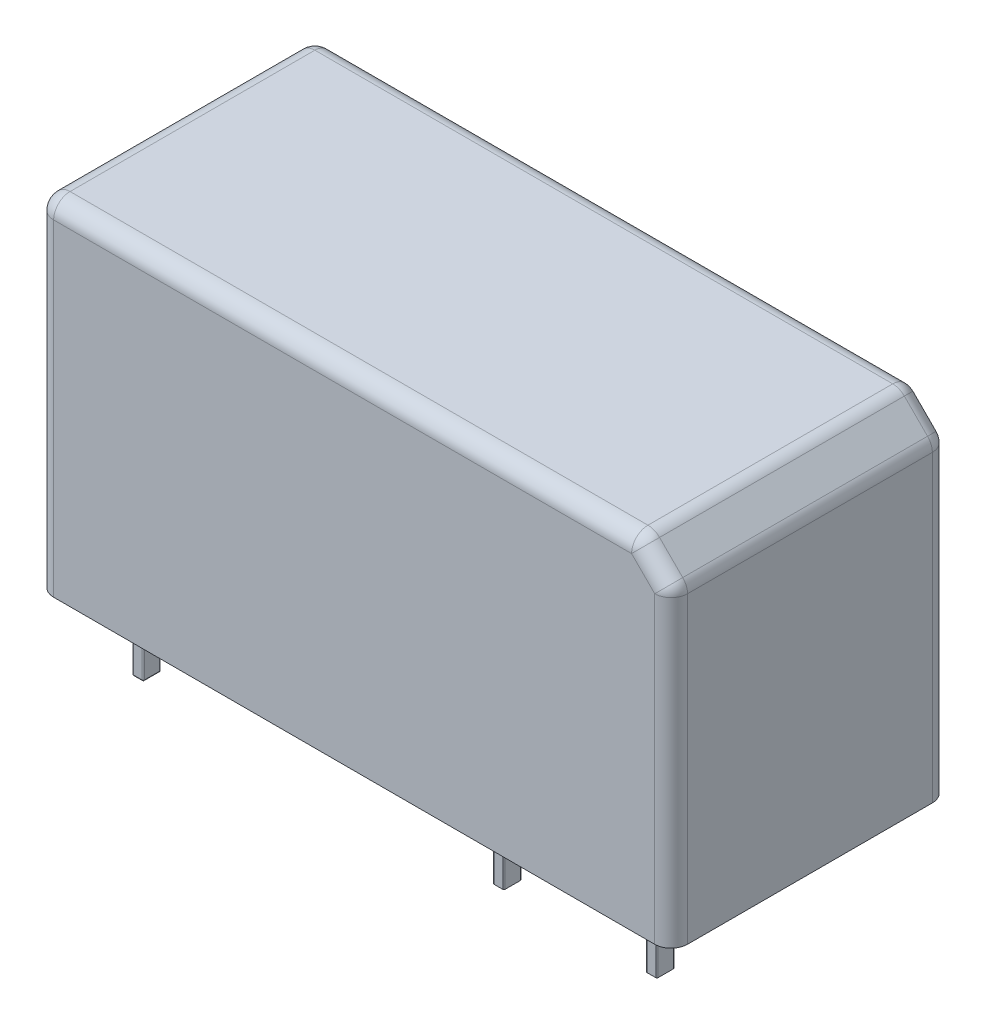
from build123d import *

# Parameters (mm, degrees)
SKETCH_1_W      = 29
SKETCH_1_H      = 12.7
EXTRUDE_1_DEPTH = 15.7
EXTRUDE_2_DEPTH = 3.5
FILLET_1_R      = 0.05
CHAMFER_1_SIZE  = 1.5
FILLET_2_R      = 0.75


with BuildPart() as part:
    # Эскиз1 → Бобышка-Вытянуть1 (new body)
    with BuildSketch(Plane(origin=(0, 0, 0), x_dir=(1, 0, 0), z_dir=(0, 1, 0))):
        Rectangle(SKETCH_1_W, SKETCH_1_H)
    extrude(amount=EXTRUDE_1_DEPTH)

    # Эскиз2 → Бобышка-Вытянуть2 (add)
    with BuildSketch(Plane.XZ):
        with BuildLine():
            Line((-12.3, 4.15), (-11.9, 4.15))
            ThreePointArc((-11.9, 4.15), (-11.864644661, 4.135355339), (-11.85, 4.1))
            Line((-11.85, 4.1), (-11.85, 3.4))
            ThreePointArc((-11.85, 3.4), (-11.864644661, 3.364644661), (-11.9, 3.35))
            Line((-11.9, 3.35), (-12.3, 3.35))
            ThreePointArc((-12.3, 3.35), (-12.335355339, 3.364644661), (-12.35, 3.4))
            Line((-12.35, 3.4), (-12.35, 4.1))
            ThreePointArc((-12.35, 4.1), (-12.335355339, 4.135355339), (-12.3, 4.15))
        make_face()
        with BuildLine():
            Line((7.65, -3.4), (7.65, -4.1))
            ThreePointArc((7.65, -4.1), (7.664644661, -4.135355339), (7.7, -4.15))
            Line((7.7, -4.15), (8.1, -4.15))
            ThreePointArc((8.1, -4.15), (8.135355339, -4.135355339), (8.15, -4.1))
            Line((8.15, -4.1), (8.15, -3.4))
            ThreePointArc((8.15, -3.4), (8.135355339, -3.364644661), (8.1, -3.35))
            Line((8.1, -3.35), (7.7, -3.35))
            ThreePointArc((7.7, -3.35), (7.664644661, -3.364644661), (7.65, -3.4))
        make_face()
        with BuildLine():
            Line((-12.35, -3.4), (-12.35, -4.1))
            ThreePointArc((-12.35, -4.1), (-12.335355339, -4.135355339), (-12.3, -4.15))
            Line((-12.3, -4.15), (-11.9, -4.15))
            ThreePointArc((-11.9, -4.15), (-11.864644661, -4.135355339), (-11.85, -4.1))
            Line((-11.85, -4.1), (-11.85, -3.4))
            ThreePointArc((-11.85, -3.4), (-11.864644661, -3.364644661), (-11.9, -3.35))
            Line((-11.9, -3.35), (-12.3, -3.35))
            ThreePointArc((-12.3, -3.35), (-12.335355339, -3.364644661), (-12.35, -3.4))
        make_face()
        with BuildLine():
            Line((11.2, 4.15), (11.6, 4.15))
            ThreePointArc((11.6, 4.15), (11.635355339, 4.135355339), (11.65, 4.1))
            Line((11.65, 4.1), (11.65, 3.4))
            ThreePointArc((11.65, 3.4), (11.635355339, 3.364644661), (11.6, 3.35))
            Line((11.6, 3.35), (11.2, 3.35))
            ThreePointArc((11.2, 3.35), (11.164644661, 3.364644661), (11.15, 3.4))
            Line((11.15, 3.4), (11.15, 4.1))
            ThreePointArc((11.15, 4.1), (11.164644661, 4.135355339), (11.2, 4.15))
        make_face()
        with BuildLine():
            Line((4.2, 4.15), (4.6, 4.15))
            ThreePointArc((4.6, 4.15), (4.635355339, 4.135355339), (4.65, 4.1))
            Line((4.65, 4.1), (4.65, 3.4))
            ThreePointArc((4.65, 3.4), (4.635355339, 3.364644661), (4.6, 3.35))
            Line((4.6, 3.35), (4.2, 3.35))
            ThreePointArc((4.2, 3.35), (4.164644661, 3.364644661), (4.15, 3.4))
            Line((4.15, 3.4), (4.15, 4.1))
            ThreePointArc((4.15, 4.1), (4.164644661, 4.135355339), (4.2, 4.15))
        make_face()
    extrude(amount=EXTRUDE_2_DEPTH)

    # Скругление1
    fillet_1_edges = [part.edges().sort_by_distance(p)[0] for p in [
        (-12.335355339, -3.5, -4.135355339),
        (-12.1, -3.5, -4.15),
        (-11.864644661, -3.5, -4.135355339),
        (-11.85, -3.5, -3.75),
        (-11.864644661, -3.5, -3.364644661),
        (-12.1, -3.5, -3.35),
        (-12.335355339, -3.5, -3.364644661),
        (-12.35, -3.5, -3.75),
        (-12.335355339, -3.5, 3.364644661),
        (-12.1, -3.5, 3.35),
        (-11.864644661, -3.5, 3.364644661),
        (-11.85, -3.5, 3.75),
        (-11.864644661, -3.5, 4.135355339),
        (-12.1, -3.5, 4.15),
        (-12.335355339, -3.5, 4.135355339),
        (-12.35, -3.5, 3.75),
        (7.664644661, -3.5, -4.135355339),
        (7.9, -3.5, -4.15),
        (8.135355339, -3.5, -4.135355339),
        (8.15, -3.5, -3.75),
        (8.135355339, -3.5, -3.364644661),
        (7.9, -3.5, -3.35),
        (7.664644661, -3.5, -3.364644661),
        (7.65, -3.5, -3.75),
    ]]
    fillet(fillet_1_edges, radius=FILLET_1_R)

    # Фаска1
    chamfer_1_edges = [part.edges().sort_by_distance(p)[0] for p in [
        (14.5, 15.7, 0),
    ]]
    chamfer(chamfer_1_edges, length=CHAMFER_1_SIZE)

    # Скругление2
    fillet_2_edges = [part.edges().sort_by_distance(p)[0] for p in [
        (-14.5, 15.7, 0),
        (-0.75, 15.7, 6.35),
        (-0.75, 15.7, -6.35),
        (13, 15.7, 0),
        (14.5, 7.1, -6.35),
        (13.75, 14.95, -6.35),
        (14.5, 7.1, 6.35),
        (14.5, 14.2, 0),
        (13.75, 14.95, 6.35),
        (-14.5, 7.85, 6.35),
        (-14.5, 7.85, -6.35),
    ]]
    fillet(fillet_2_edges, radius=FILLET_2_R)


solid = part.part
